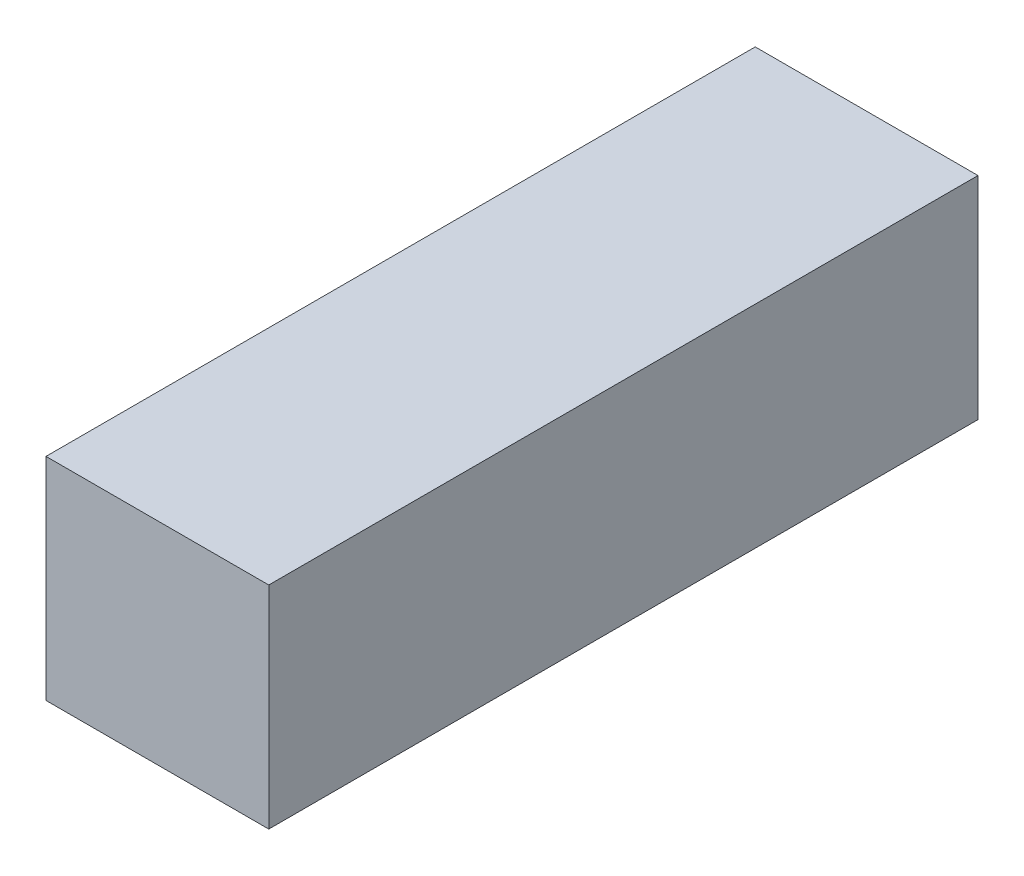
from build123d import *

# Parameters (mm, degrees)
SKETCH1_W           = 49
SKETCH1_H           = 46.5
BOSS_EXTRUDE1_DEPTH = 156


with BuildPart() as part:
    # Sketch1 → Boss-Extrude1 (new body)
    with BuildSketch(Plane.XY):
        Rectangle(SKETCH1_W, SKETCH1_H)
    extrude(amount=BOSS_EXTRUDE1_DEPTH)


solid = part.part
